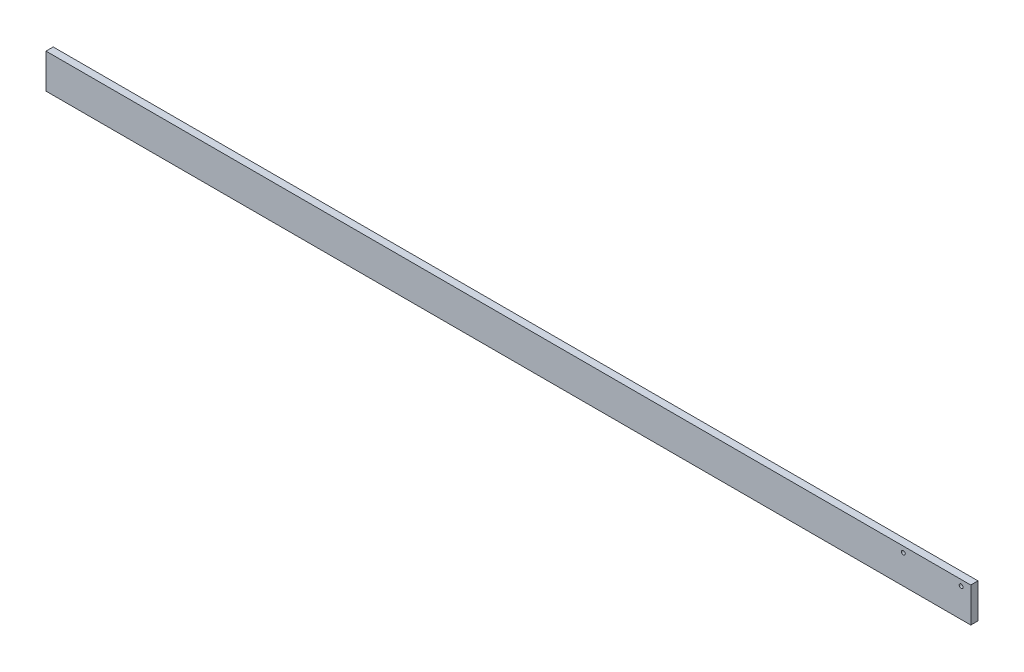
from build123d import *

# Parameters (mm, degrees)
SKETCH1_W           = 609.6
SKETCH1_H           = 22.86
BOSS_EXTRUDE1_DEPTH = 2.38125
SKETCH4_R           = 1.27
CUT_EXTRUDE3_DEPTH  = 5.7625


with BuildPart() as part:
    # Sketch1 → Boss-Extrude1 (new body, symmetric)
    with BuildSketch(Plane.XY):
        Rectangle(SKETCH1_W, SKETCH1_H)
    extrude(amount=BOSS_EXTRUDE1_DEPTH, both=True)

    # Sketch4 → Cut-Extrude3 (cut, through all)
    with BuildSketch(Plane.XY.offset(2.38125)):
        with Locations((260.35, 7.62)):
            Circle(SKETCH4_R)
        with Locations((298.45, 7.62)):
            Circle(SKETCH4_R)
    extrude(amount=-CUT_EXTRUDE3_DEPTH, mode=Mode.SUBTRACT)


solid = part.part
